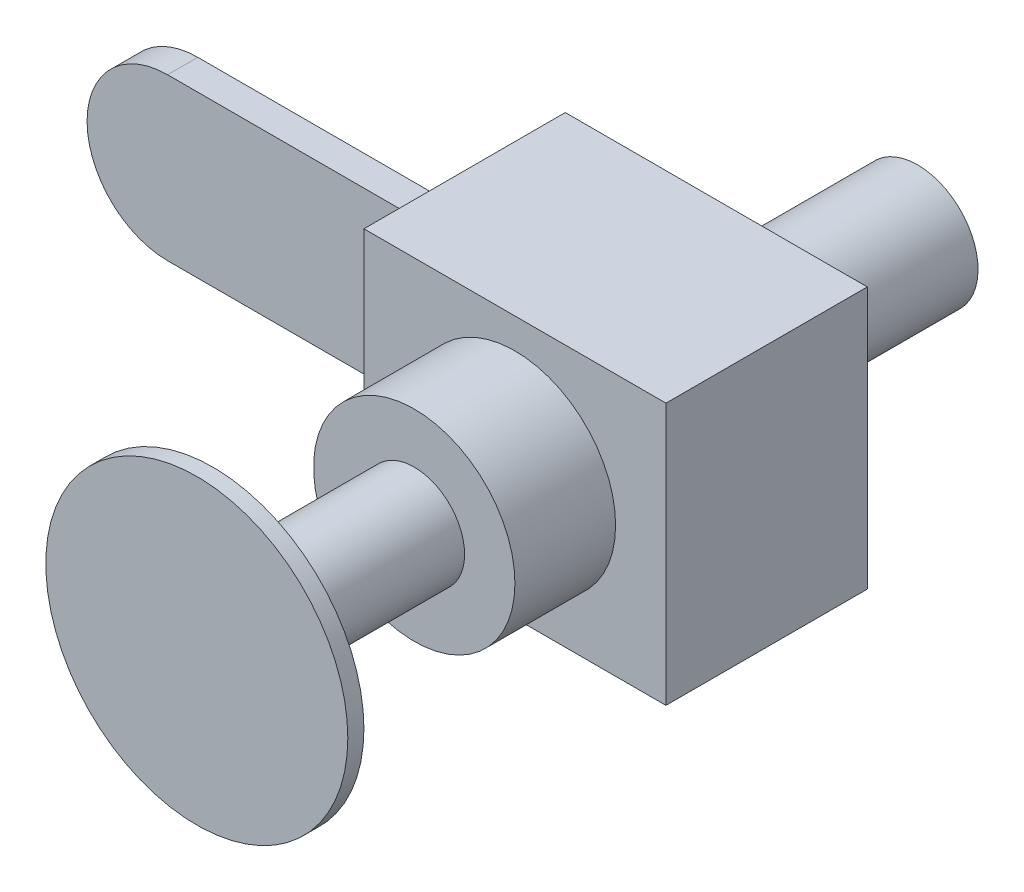
from build123d import *

# Parameters (mm, degrees)
BOSS_EXTRUDE1_DEPTH = 7.5
SKETCH3_W           = 100
SKETCH3_H           = 130
BOSS_EXTRUDE2_DEPTH = 150
SKETCH4_R           = 30
BOSS_EXTRUDE3_DEPTH = 100
SKETCH5_R           = 50
BOSS_EXTRUDE4_DEPTH = 50
SKETCH6_R           = 25
BOSS_EXTRUDE5_DEPTH = 100
SKETCH7_R           = 75
BOSS_EXTRUDE6_DEPTH = 8


with BuildPart() as part:
    # Sketch1 → Boss-Extrude1 (new body, symmetric)
    with BuildSketch(Plane.XY):
        with BuildLine():
            Line((0, 40), (140, 40))
            Line((140, 40), (140, -40))
            Line((140, -40), (0, -40))
            ThreePointArc((0, -40), (-40, 0), (0, 40))
        make_face()
    extrude(amount=BOSS_EXTRUDE1_DEPTH, both=True)

    # Sketch3 → Boss-Extrude2 (add)
    with BuildSketch(Plane(origin=(140, 0, 0), x_dir=(0, 0, -1), z_dir=(1, 0, 0))):
        Rectangle(SKETCH3_W, SKETCH3_H)
    extrude(amount=BOSS_EXTRUDE2_DEPTH)

    # Sketch4 → Boss-Extrude3 (add)
    with BuildSketch(Plane(origin=(0, 0, -50), x_dir=(-1, 0, 0), z_dir=(0, 0, -1))):
        with Locations((-215, 0)):
            Circle(SKETCH4_R)
    extrude(amount=BOSS_EXTRUDE3_DEPTH)

    # Sketch5 → Boss-Extrude4 (add)
    with BuildSketch(Plane.XY.offset(50)):
        with Locations((215, 0)):
            Circle(SKETCH5_R)
    extrude(amount=BOSS_EXTRUDE4_DEPTH)

    # Sketch6 → Boss-Extrude5 (add)
    with BuildSketch(Plane.XY.offset(100)):
        with Locations((215, 0)):
            Circle(SKETCH6_R)
    extrude(amount=BOSS_EXTRUDE5_DEPTH)

    # Sketch7 → Boss-Extrude6 (add)
    with BuildSketch(Plane.XY.offset(200)):
        with Locations((215, 0)):
            Circle(SKETCH7_R)
    extrude(amount=BOSS_EXTRUDE6_DEPTH)


solid = part.part
